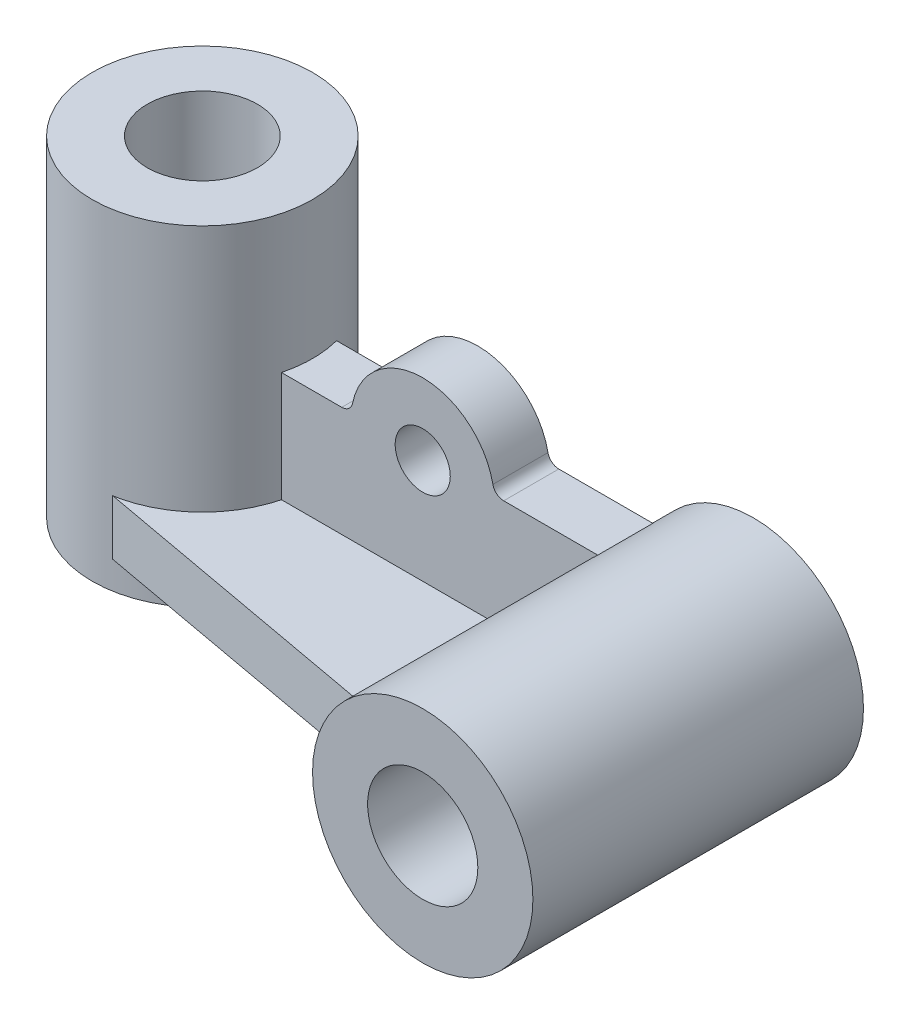
from build123d import *

# Parameters (mm, degrees)
SKETCH3_R         = 20
SKETCH3_R_2       = 10
CYL_BLUE_DEPTH    = 60
SKETCH4_R         = 5
BASE_YELLOW_DEPTH = 10
BASE_RED_DEPTH    = 10
SKETCH7_R         = 20
SKETCH7_R_2       = 10
CYL_PURPLE_DEPTH  = 60


with BuildPart() as part:
    # Sketch3 → cyl- blue (new body)
    with BuildSketch(Plane.XY.offset(50)):
        with Locations((90, -10)):
            Circle(SKETCH3_R)
        with Locations((90, -10)):
            Circle(SKETCH3_R_2, mode=Mode.SUBTRACT)
    extrude(amount=-CYL_BLUE_DEPTH)


with BuildPart() as body_2:
    # Sketch4 → base- yellow (new body)
    with BuildSketch(Plane.XY.offset(-5)):
        with BuildLine():
            Line((10, -15), (70.635083269, -15))
            ThreePointArc((70.635083269, -15), (70.879673523, -4.133730706), (76.771243445, 5))
            Line((76.771243445, 5), (59.696938457, 5))
            ThreePointArc((59.696938457, 5), (58.432027393, 5.450806662), (57.737346662, 6.6))
            ThreePointArc((57.737346662, 6.6), (45, 17), (32.262653338, 6.6))
            ThreePointArc((32.262653338, 6.6), (31.567972607, 5.450806662), (30.303061543, 5))
            Line((30.303061543, 5), (10, 5))
            Line((10, 5), (10, -15))
        make_face()
        with Locations((45, 4)):
            Circle(SKETCH4_R, mode=Mode.SUBTRACT)
    extrude(amount=BASE_YELLOW_DEPTH)

    # Sketch7 → cyl-purple (add)
    with BuildSketch(Plane(origin=(0, -30, 0), x_dir=(1, 0, 0), z_dir=(0, 1, 0))):
        Circle(SKETCH7_R)
        Circle(SKETCH7_R_2, mode=Mode.SUBTRACT)
    extrude(amount=CYL_PURPLE_DEPTH)


with BuildPart() as body_3:
    # Sketch6 → base-red (new body)
    with BuildSketch(Plane(origin=(0, -25, 0), x_dir=(1, 0, 0), z_dir=(0, 1, 0))):
        Polygon((11, -5), (76, -5), (76, -30), (60, -30), (-4.339296012, -18.261867577), align=None)
    extrude(amount=BASE_RED_DEPTH)


solid = Compound([part.part, body_2.part, body_3.part])
